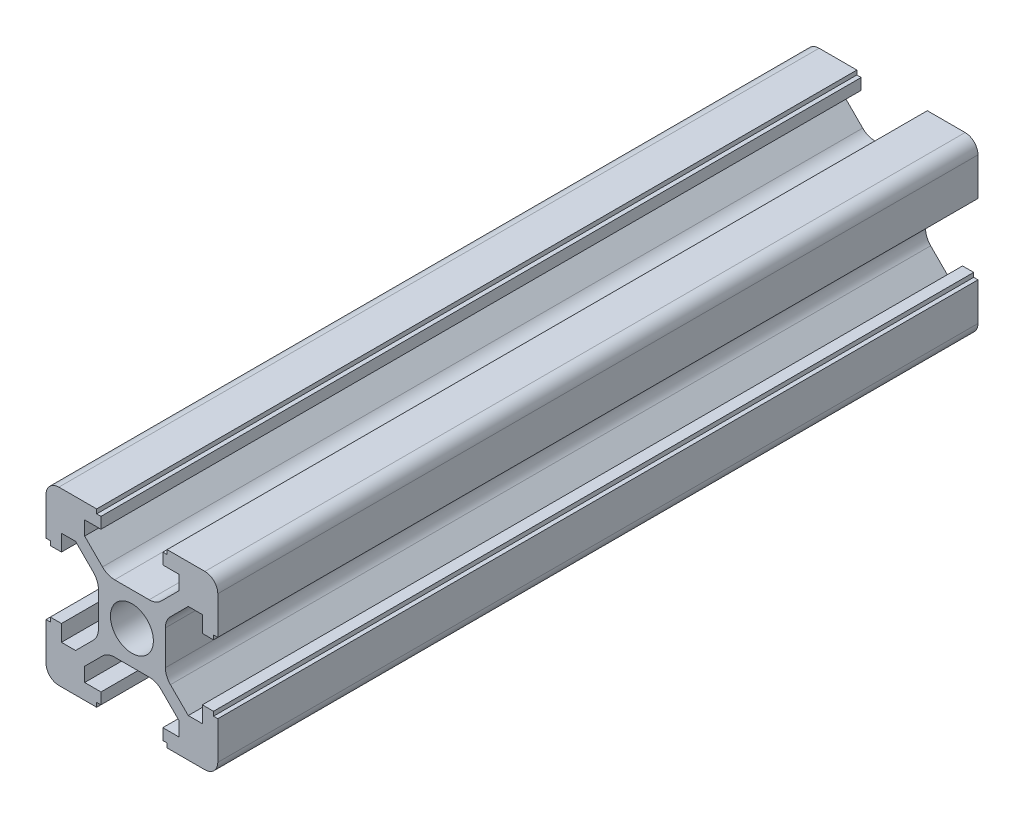
from build123d import *

# Parameters (mm, degrees)
SKETCH1_R           = 2.5
BOSS_EXTRUDE2_DEPTH = 88.5


with BuildPart() as part:
    # Sketch1 → Boss-Extrude2 (new body)
    with BuildSketch(Plane.XY):
        with BuildLine():
            Line((10, -4.1), (10, -8.5))
            ThreePointArc((10, -8.5), (9.560660172, -9.560660172), (8.5, -10))
            Line((8.5, -10), (4.1, -10))
            Line((4.1, -10), (4.1, -9.5))
            Line((4.1, -9.5), (3.6, -9.5))
            Line((3.6, -9.5), (3.6, -8.2))
            Line((3.6, -8.2), (5.5, -8.2))
            Line((5.5, -8.2), (5.5, -6.560660172))
            Line((5.5, -6.560660172), (3.425126266, -4.485786438))
            ThreePointArc((3.425126266, -4.485786438), (2.776279568, -4.052240935), (2.010912703, -3.9))
            Line((2.010912703, -3.9), (-2.010912703, -3.9))
            ThreePointArc((-2.010912703, -3.9), (-2.776279568, -4.052240935), (-3.425126266, -4.485786438))
            Line((-3.425126266, -4.485786438), (-5.5, -6.560660172))
            Line((-5.5, -6.560660172), (-5.5, -8.2))
            Line((-5.5, -8.2), (-3.6, -8.2))
            Line((-3.6, -8.2), (-3.6, -9.5))
            Line((-3.6, -9.5), (-4.1, -9.5))
            Line((-4.1, -9.5), (-4.1, -10))
            Line((-4.1, -10), (-8.5, -10))
            ThreePointArc((-8.5, -10), (-9.560660172, -9.560660172), (-10, -8.5))
            Line((-10, -8.5), (-10, -4.1))
            Line((-10, -4.1), (-9.5, -4.1))
            Line((-9.5, -4.1), (-9.5, -3.6))
            Line((-9.5, -3.6), (-8.2, -3.6))
            Line((-8.2, -3.6), (-8.2, -5.5))
            Line((-8.2, -5.5), (-6.560660172, -5.5))
            Line((-6.560660172, -5.5), (-4.485786438, -3.425126266))
            ThreePointArc((-4.485786438, -3.425126266), (-4.052240935, -2.776279568), (-3.9, -2.010912703))
            Line((-3.9, -2.010912703), (-3.9, 2.010912703))
            ThreePointArc((-3.9, 2.010912703), (-4.052240935, 2.776279568), (-4.485786438, 3.425126266))
            Line((-4.485786438, 3.425126266), (-6.560660172, 5.5))
            Line((-6.560660172, 5.5), (-8.2, 5.5))
            Line((-8.2, 5.5), (-8.2, 3.6))
            Line((-8.2, 3.6), (-9.5, 3.6))
            Line((-9.5, 3.6), (-9.5, 4.1))
            Line((-9.5, 4.1), (-10, 4.1))
            Line((-10, 4.1), (-10, 8.5))
            ThreePointArc((-10, 8.5), (-9.560660172, 9.560660172), (-8.5, 10))
            Line((-8.5, 10), (-4.1, 10))
            Line((-4.1, 10), (-4.1, 9.5))
            Line((-4.1, 9.5), (-3.6, 9.5))
            Line((-3.6, 9.5), (-3.6, 8.2))
            Line((-3.6, 8.2), (-5.5, 8.2))
            Line((-5.5, 8.2), (-5.5, 6.560660172))
            Line((-5.5, 6.560660172), (-3.425126266, 4.485786438))
            ThreePointArc((-3.425126266, 4.485786438), (-2.776279568, 4.052240935), (-2.010912703, 3.9))
            Line((-2.010912703, 3.9), (2.010912703, 3.9))
            ThreePointArc((2.010912703, 3.9), (2.776279568, 4.052240935), (3.425126266, 4.485786438))
            Line((3.425126266, 4.485786438), (5.5, 6.560660172))
            Line((5.5, 6.560660172), (5.5, 8.2))
            Line((5.5, 8.2), (3.6, 8.2))
            Line((3.6, 8.2), (3.6, 9.5))
            Line((3.6, 9.5), (4.1, 9.5))
            Line((4.1, 9.5), (4.1, 10))
            Line((4.1, 10), (8.5, 10))
            ThreePointArc((8.5, 10), (9.560660172, 9.560660172), (10, 8.5))
            Line((10, 8.5), (10, 4.1))
            Line((10, 4.1), (9.5, 4.1))
            Line((9.5, 4.1), (9.5, 3.6))
            Line((9.5, 3.6), (8.2, 3.6))
            Line((8.2, 3.6), (8.2, 5.5))
            Line((8.2, 5.5), (6.560660172, 5.5))
            Line((6.560660172, 5.5), (4.485786438, 3.425126266))
            ThreePointArc((4.485786438, 3.425126266), (4.052240935, 2.776279568), (3.9, 2.010912703))
            Line((3.9, 2.010912703), (3.9, -2.010912703))
            ThreePointArc((3.9, -2.010912703), (4.052240935, -2.776279568), (4.485786438, -3.425126266))
            Line((4.485786438, -3.425126266), (6.560660172, -5.5))
            Line((6.560660172, -5.5), (8.2, -5.5))
            Line((8.2, -5.5), (8.2, -3.6))
            Line((8.2, -3.6), (9.5, -3.6))
            Line((9.5, -3.6), (9.5, -4.1))
            Line((9.5, -4.1), (10, -4.1))
        make_face()
        Circle(SKETCH1_R, mode=Mode.SUBTRACT)
    extrude(amount=BOSS_EXTRUDE2_DEPTH)


solid = part.part
